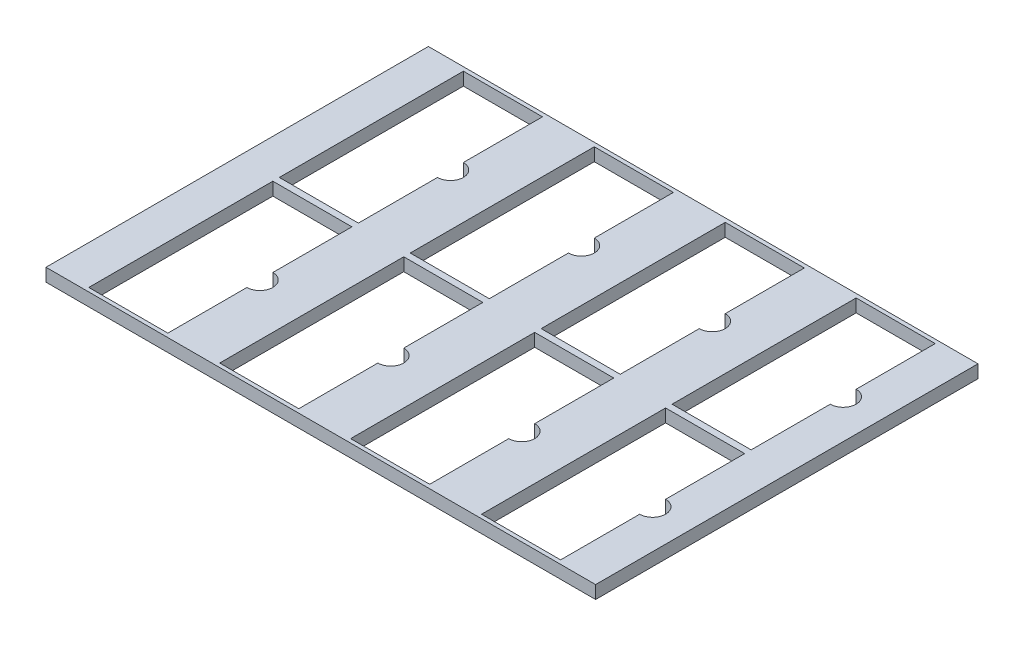
from build123d import *

# Parameters (mm, degrees)
SKETCH1_W           = 424
SKETCH1_H           = 295
BOSS_EXTRUDE1_DEPTH = 10


with BuildPart() as part:
    # Sketch1 → Boss-Extrude1 (new body)
    with BuildSketch(Plane(origin=(0, 0, 0), x_dir=(1, 0, 0), z_dir=(0, 1, 0))):
        Rectangle(SKETCH1_W, SKETCH1_H)
        with BuildLine():
            Line((-182, 144.5), (-121, 144.5))
            Line((-121, 144.5), (-121, 83.5))
            ThreePointArc((-121, 83.5), (-111, 73.5), (-121, 63.5))
            Line((-121, 63.5), (-121, 2.5))
            Line((-121, 2.5), (-182, 2.5))
            Line((-182, 2.5), (-182, 144.5))
        make_face(mode=Mode.SUBTRACT)
        with BuildLine():
            Line((-20, 63.5), (-20, 2.5))
            Line((-20, 2.5), (-81, 2.5))
            Line((-81, 2.5), (-81, 144.5))
            Line((-81, 144.5), (-20, 144.5))
            Line((-20, 144.5), (-20, 83.5))
            ThreePointArc((-20, 83.5), (-10, 73.5), (-20, 63.5))
        make_face(mode=Mode.SUBTRACT)
        with BuildLine():
            Line((81, 63.5), (81, 2.5))
            Line((81, 2.5), (20, 2.5))
            Line((20, 2.5), (20, 144.5))
            Line((20, 144.5), (81, 144.5))
            Line((81, 144.5), (81, 83.5))
            ThreePointArc((81, 83.5), (91, 73.5), (81, 63.5))
        make_face(mode=Mode.SUBTRACT)
        with BuildLine():
            Line((182, 63.5), (182, 2.5))
            Line((182, 2.5), (121, 2.5))
            Line((121, 2.5), (121, 144.5))
            Line((121, 144.5), (182, 144.5))
            Line((182, 144.5), (182, 83.5))
            ThreePointArc((182, 83.5), (192, 73.5), (182, 63.5))
        make_face(mode=Mode.SUBTRACT)
        with BuildLine():
            Line((-20, -63.5), (-20, -2.5))
            Line((-20, -2.5), (-81, -2.5))
            Line((-81, -2.5), (-81, -144.5))
            Line((-81, -144.5), (-20, -144.5))
            Line((-20, -144.5), (-20, -83.5))
            ThreePointArc((-20, -83.5), (-10, -73.5), (-20, -63.5))
        make_face(mode=Mode.SUBTRACT)
        with BuildLine():
            Line((-121, -144.5), (-121, -83.5))
            ThreePointArc((-121, -83.5), (-111, -73.5), (-121, -63.5))
            Line((-121, -63.5), (-121, -2.5))
            Line((-121, -2.5), (-182, -2.5))
            Line((-182, -2.5), (-182, -144.5))
            Line((-182, -144.5), (-121, -144.5))
        make_face(mode=Mode.SUBTRACT)
        with BuildLine():
            Line((81, -63.5), (81, -2.5))
            Line((81, -2.5), (20, -2.5))
            Line((20, -2.5), (20, -144.5))
            Line((20, -144.5), (81, -144.5))
            Line((81, -144.5), (81, -83.5))
            ThreePointArc((81, -83.5), (91, -73.5), (81, -63.5))
        make_face(mode=Mode.SUBTRACT)
        with BuildLine():
            Line((182, -63.5), (182, -2.5))
            Line((182, -2.5), (121, -2.5))
            Line((121, -2.5), (121, -144.5))
            Line((121, -144.5), (182, -144.5))
            Line((182, -144.5), (182, -83.5))
            ThreePointArc((182, -83.5), (192, -73.5), (182, -63.5))
        make_face(mode=Mode.SUBTRACT)
    extrude(amount=BOSS_EXTRUDE1_DEPTH)


solid = part.part
